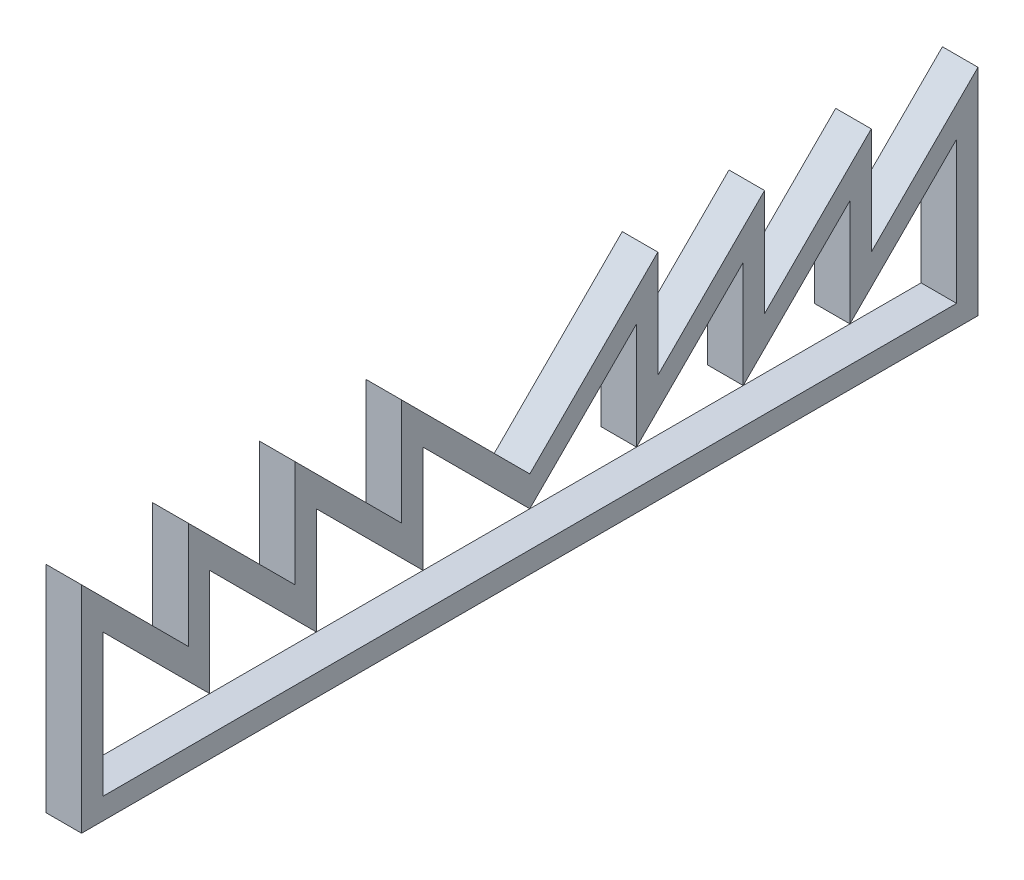
from build123d import *

# Parameters (mm, degrees)
BOSS_EXTRUDE1_DEPTH = 12.7


with BuildPart() as part:
    # Sketch1 → Boss-Extrude1 (new body)
    with BuildSketch(Plane(origin=(0, 0, 0), x_dir=(0, 0, -1), z_dir=(1, 0, 0))):
        Polygon((-160.02, -7.62), (-160.02, 69.196307345), (-121.92, 31.096307345), (-121.92, 69.196307345), (-83.82, 31.096307345), (-83.82, 69.196307345), (-45.72, 31.096307345), (-45.72, 69.196307345), (0, 23.476307345), (45.72, 69.196307345), (45.72, 31.096307345), (83.82, 69.196307345), (83.82, 31.096307345), (121.92, 69.196307345), (121.92, 31.096307345), (160.02, 69.196307345), (160.02, -7.62), align=None)
        Polygon((38.1, 12.7), (38.1, 50.8), (0, 12.7), (-38.1, 50.8), (-38.1, 12.7), (-76.2, 50.8), (-76.2, 12.7), (-114.3, 50.8), (-114.3, 12.7), (-152.4, 50.8), (-152.4, 0), (152.4, 0), (152.4, 50.8), (114.3, 12.7), (114.3, 50.8), (76.2, 12.7), (76.2, 50.8), align=None, mode=Mode.SUBTRACT)
    extrude(amount=BOSS_EXTRUDE1_DEPTH)


solid = part.part
